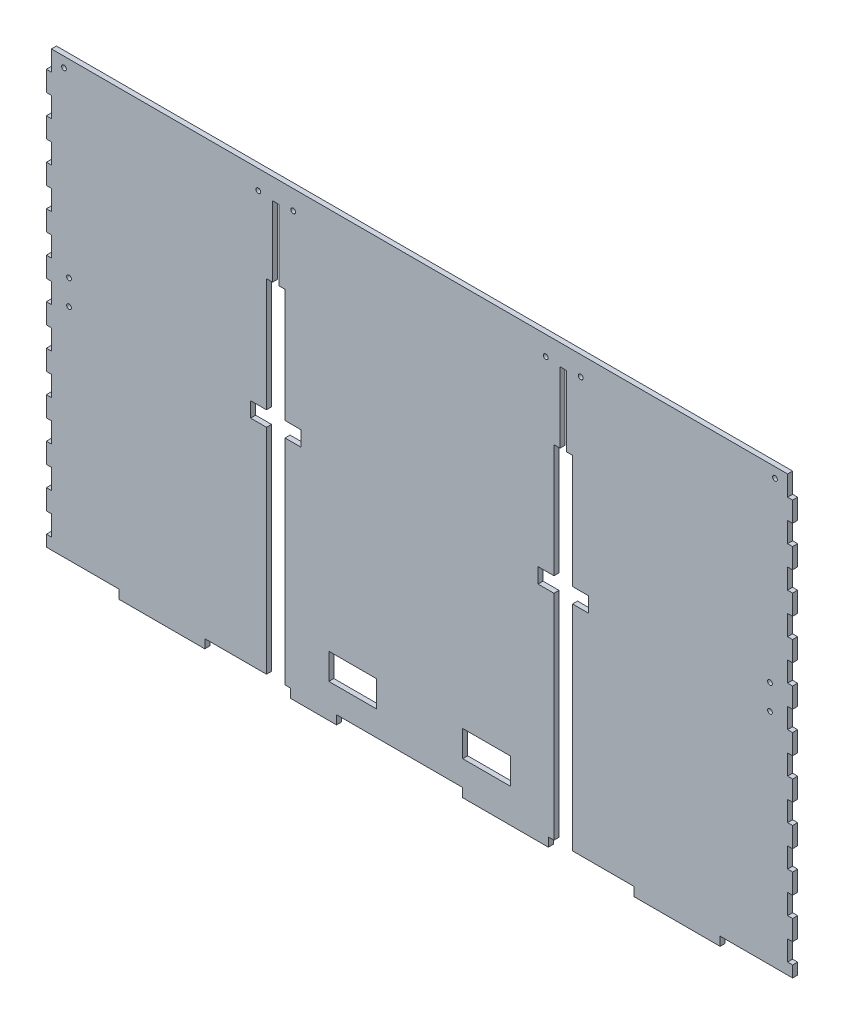
from build123d import *

# Parameters (mm, degrees)
SKETCH1_W                    = 3.175
SKETCH1_H                    = 12.7
MAIN_EXTRUDE_DEPTH           = 3.175
SKETCH8_R                    = 1.5
SKETCH8_W                    = 3.175
SKETCH8_H                    = 31.877
MOUNT_HOLES_DEPTH            = 430.752406189
DOOR_SLOTS_DEPTH             = 430.752406189
SKETCH10_R                   = 1.5
DOOR_GUIDE_MOUNT_HOLES_DEPTH = 430.752406189
SKETCH12_R                   = 1.5
EXTENSION_CLIP_HOLES_DEPTH   = 430.752406189
EXTENSION_CENTER_CUT_DEPTH   = 430.752406189
SKETCH17_W                   = 30.1
SKETCH17_H                   = 16.51
SKETCH17_W_2                 = 25.230666667
SKETCH17_H_2                 = 5.588
NOSEPOKES_SCOPED_DEPTH       = 274.745760251


with BuildPart() as part:
    # Sketch1 → Main Extrude (new body)
    with BuildSketch(Plane.XY):
        Polygon((-381, 139.7), (-406.4, 139.7), (-406.4, -139.7), (-352.213333333, -139.7), (-352.213333333, -134.112), (-298.026666667, -134.112), (-298.026666667, -139.7), (-243.84, -139.7), (-243.84, -134.112), (-189.653333333, -134.112), (-189.653333333, -139.7), (-135.466666667, -139.7), (-135.466666667, -134.112), (-81.28, -134.112), (-81.28, -139.7), (-27.093333333, -139.7), (-27.093333333, -134.112), (27.093333333, -134.112), (27.093333333, -139.7), (81.28, -139.7), (81.28, -134.112), (135.466666667, -134.112), (135.466666667, -139.7), (189.653333333, -139.7), (189.653333333, -134.112), (243.84, -134.112), (243.84, -139.7), (298.026666667, -139.7), (298.026666667, -134.112), (352.213333333, -134.112), (352.213333333, -139.7), (406.4, -139.7), (406.4, 139.7), (381, 139.7), (381, 127), (377.825, 127), (377.825, 139.7), (-377.825, 139.7), (-377.825, 127), (-381, 127), align=None)
        with Locations((-379.4125, 107.95)):
            Rectangle(SKETCH1_W, SKETCH1_H, mode=Mode.SUBTRACT)
        with Locations((-379.4125, 82.55)):
            Rectangle(SKETCH1_W, SKETCH1_H, mode=Mode.SUBTRACT)
        with Locations((-379.4125, 57.15)):
            Rectangle(SKETCH1_W, SKETCH1_H, mode=Mode.SUBTRACT)
        with Locations((-379.4125, 31.75)):
            Rectangle(SKETCH1_W, SKETCH1_H, mode=Mode.SUBTRACT)
        with Locations((-379.4125, 6.35)):
            Rectangle(SKETCH1_W, SKETCH1_H, mode=Mode.SUBTRACT)
        with Locations((-379.4125, -19.05)):
            Rectangle(SKETCH1_W, SKETCH1_H, mode=Mode.SUBTRACT)
        with Locations((-379.4125, -44.45)):
            Rectangle(SKETCH1_W, SKETCH1_H, mode=Mode.SUBTRACT)
        with Locations((-379.4125, -69.85)):
            Rectangle(SKETCH1_W, SKETCH1_H, mode=Mode.SUBTRACT)
        with Locations((-379.4125, -95.25)):
            Rectangle(SKETCH1_W, SKETCH1_H, mode=Mode.SUBTRACT)
        with Locations((-379.4125, -120.65)):
            Rectangle(SKETCH1_W, SKETCH1_H, mode=Mode.SUBTRACT)
        with Locations((379.4125, 107.95)):
            Rectangle(SKETCH1_W, SKETCH1_H, mode=Mode.SUBTRACT)
        with Locations((379.4125, 82.55)):
            Rectangle(SKETCH1_W, SKETCH1_H, mode=Mode.SUBTRACT)
        with Locations((379.4125, 57.15)):
            Rectangle(SKETCH1_W, SKETCH1_H, mode=Mode.SUBTRACT)
        with Locations((379.4125, 31.75)):
            Rectangle(SKETCH1_W, SKETCH1_H, mode=Mode.SUBTRACT)
        with Locations((379.4125, 6.35)):
            Rectangle(SKETCH1_W, SKETCH1_H, mode=Mode.SUBTRACT)
        with Locations((379.4125, -19.05)):
            Rectangle(SKETCH1_W, SKETCH1_H, mode=Mode.SUBTRACT)
        with Locations((379.4125, -44.45)):
            Rectangle(SKETCH1_W, SKETCH1_H, mode=Mode.SUBTRACT)
        with Locations((379.4125, -69.85)):
            Rectangle(SKETCH1_W, SKETCH1_H, mode=Mode.SUBTRACT)
        with Locations((379.4125, -95.25)):
            Rectangle(SKETCH1_W, SKETCH1_H, mode=Mode.SUBTRACT)
        with Locations((379.4125, -120.65)):
            Rectangle(SKETCH1_W, SKETCH1_H, mode=Mode.SUBTRACT)
    extrude(amount=MAIN_EXTRUDE_DEPTH)

    # Sketch8 → Mount Holes (cut, through all)
    with BuildSketch(Plane.XY.offset(3.175)):
        with Locations((-393.7, -120.65)):
            Circle(SKETCH8_R)
        with Locations((393.7, -120.65)):
            Circle(SKETCH8_R)
        with Locations((-382.5875, 12.319)):
            Rectangle(SKETCH8_W, SKETCH8_H)
        with Locations((382.5875, 12.319)):
            Rectangle(SKETCH8_W, SKETCH8_H)
    extrude(amount=-MOUNT_HOLES_DEPTH, mode=Mode.SUBTRACT)

    # Sketch3 → Door Slots (cut, through all)
    with BuildSketch(Plane.XY.offset(3.175)):
        Polygon((-88.7095, 126.492), (-92.6465, 126.492), (-92.6465, 82.042), (-96.52, 82.042), (-96.52, 10.3505), (-106.553, 10.3505), (-106.553, 0.8255), (-96.52, 0.8255), (-96.52, -134.112), (-84.836, -134.112), (-84.836, 0.8255), (-74.803, 0.8255), (-74.803, 10.3505), (-84.836, 10.3505), (-84.836, 82.042), (-88.7095, 82.042), align=None)
        Polygon((92.6465, 126.492), (88.7095, 126.492), (88.7095, 82.042), (84.836, 82.042), (84.836, 10.3505), (74.803, 10.3505), (74.803, 0.8255), (84.836, 0.8255), (84.836, -134.112), (96.52, -134.112), (96.52, 0.8255), (106.553, 0.8255), (106.553, 10.3505), (96.52, 10.3505), (96.52, 82.042), (92.6465, 82.042), align=None)
    extrude(amount=-DOOR_SLOTS_DEPTH, mode=Mode.SUBTRACT)

    # Sketch10 → Door Guide Mount Holes (cut, through all)
    with BuildSketch(Plane.XY.offset(3.175)):
        with Locations((-101.678, 127.492)):
            Circle(SKETCH10_R)
        with Locations((-79.678, 127.492)):
            Circle(SKETCH10_R)
        with Locations((79.678, 127.492)):
            Circle(SKETCH10_R)
        with Locations((101.678, 127.492)):
            Circle(SKETCH10_R)
    extrude(amount=-DOOR_GUIDE_MOUNT_HOLES_DEPTH, mode=Mode.SUBTRACT)

    # Sketch12 → Extension Clip Holes (cut, through all)
    with BuildSketch(Plane.XY.offset(3.175)):
        with Locations((-246.507, 20.193)):
            Circle(SKETCH12_R)
        with Locations((-246.507, 4.445)):
            Circle(SKETCH12_R)
        with Locations((-221.107, 4.445)):
            Circle(SKETCH12_R)
        with Locations((-221.107, 20.193)):
            Circle(SKETCH12_R)
        with Locations((-243.332, 133.35)):
            Circle(SKETCH12_R)
        with Locations((-224.282, 133.35)):
            Circle(SKETCH12_R)
        with Locations((224.282, 133.35)):
            Circle(SKETCH12_R)
        with Locations((243.332, 133.35)):
            Circle(SKETCH12_R)
        with Locations((221.107, 20.193)):
            Circle(SKETCH12_R)
        with Locations((221.107, 4.445)):
            Circle(SKETCH12_R)
        with Locations((246.507, 4.445)):
            Circle(SKETCH12_R)
        with Locations((246.507, 20.193)):
            Circle(SKETCH12_R)
    extrude(amount=-EXTENSION_CLIP_HOLES_DEPTH, mode=Mode.SUBTRACT)

    # Sketch11_3 → Extension Center Cut (cut, through all)
    with BuildSketch(Plane.XY.offset(3.175)):
        Polygon((-232.2195, 127), (-232.2195, 139.7), (-406.4, 139.7), (-406.4, -139.7), (-235.3945, -139.7), (-235.3945, -127), (-232.2195, -127), (-232.2195, -114.3), (-235.3945, -114.3), (-235.3945, -101.6), (-232.2195, -101.6), (-232.2195, -88.9), (-235.3945, -88.9), (-235.3945, -76.2), (-232.2195, -76.2), (-232.2195, -63.5), (-235.3945, -63.5), (-235.3945, -50.8), (-232.2195, -50.8), (-232.2195, -38.1), (-235.3945, -38.1), (-235.3945, -25.4), (-232.2195, -25.4), (-232.2195, -12.7), (-235.3945, -12.7), (-235.3945, 0), (-232.2195, 0), (-232.2195, 12.7), (-235.3945, 12.7), (-235.3945, 25.4), (-232.2195, 25.4), (-232.2195, 38.1), (-235.3945, 38.1), (-235.3945, 50.8), (-232.2195, 50.8), (-232.2195, 63.5), (-235.3945, 63.5), (-235.3945, 76.2), (-232.2195, 76.2), (-232.2195, 88.9), (-235.3945, 88.9), (-235.3945, 101.6), (-232.2195, 101.6), (-232.2195, 114.3), (-235.3945, 114.3), (-235.3945, 127), align=None)
        Polygon((406.4, 139.7), (232.2195, 139.7), (232.2195, 127), (235.3945, 127), (235.3945, 114.3), (232.2195, 114.3), (232.2195, 101.6), (235.3945, 101.6), (235.3945, 88.9), (232.2195, 88.9), (232.2195, 76.2), (235.3945, 76.2), (235.3945, 63.5), (232.2195, 63.5), (232.2195, 50.8), (235.3945, 50.8), (235.3945, 38.1), (232.2195, 38.1), (232.2195, 25.4), (235.3945, 25.4), (235.3945, 12.7), (232.2195, 12.7), (232.2195, 0), (235.3945, 0), (235.3945, -12.7), (232.2195, -12.7), (232.2195, -25.4), (235.3945, -25.4), (235.3945, -38.1), (232.2195, -38.1), (232.2195, -50.8), (235.3945, -50.8), (235.3945, -63.5), (232.2195, -63.5), (232.2195, -76.2), (235.3945, -76.2), (235.3945, -88.9), (232.2195, -88.9), (232.2195, -101.6), (235.3945, -101.6), (235.3945, -114.3), (232.2195, -114.3), (232.2195, -127), (235.3945, -127), (235.3945, -139.7), (406.4, -139.7), align=None)
    extrude(amount=-EXTENSION_CENTER_CUT_DEPTH, mode=Mode.SUBTRACT)

    # Sketch17 → nosepokes_scoped (cut, through all)
    with BuildSketch(Plane.XY.offset(3.175)):
        with Locations((42.291, -110.109)):
            Rectangle(SKETCH17_W, SKETCH17_H)
        with Locations((-42.164, -110.109)):
            Rectangle(SKETCH17_W, SKETCH17_H)
        with Locations((-39.708666667, -136.906)):
            Rectangle(SKETCH17_W_2, SKETCH17_H_2)
    extrude(amount=-NOSEPOKES_SCOPED_DEPTH, mode=Mode.SUBTRACT)


solid = part.part
